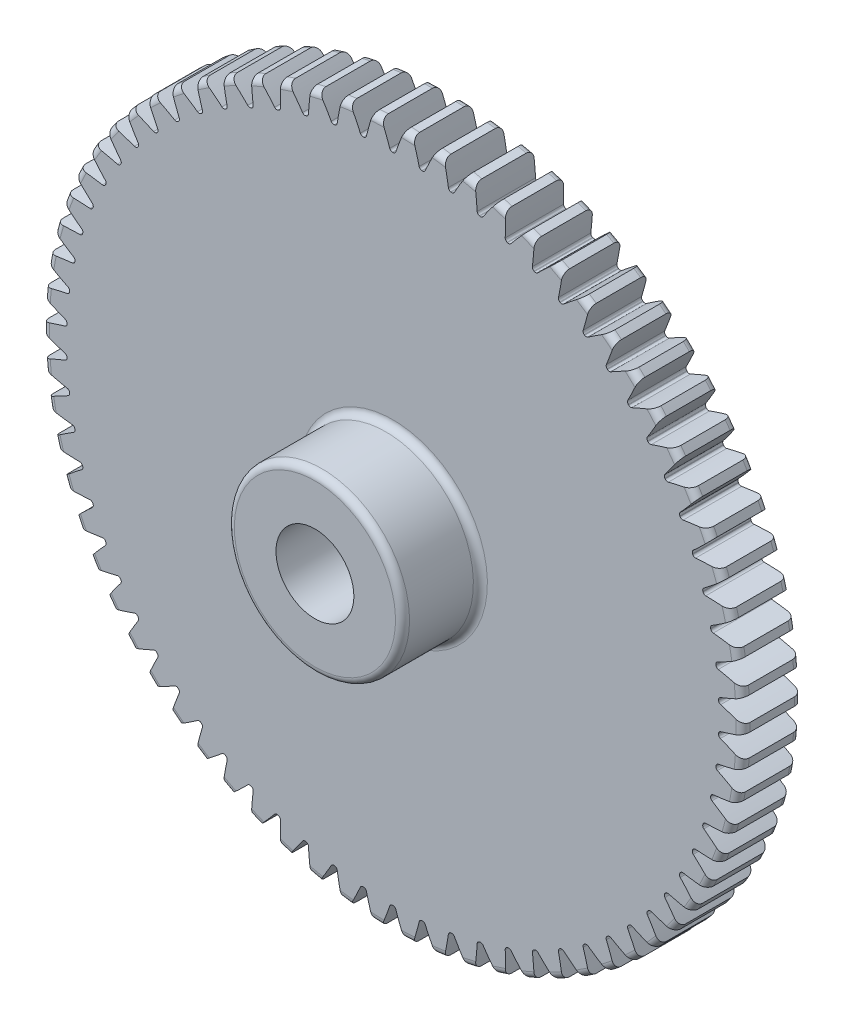
from build123d import *

# Parameters (mm, degrees)
FILLET2_R          = 0.72
CUT_EXTRUDE2_DEPTH = 7
CIRPATTERN1_COUNT  = 70


with BuildPart() as part:
    # Sketch4 → Revolve1 (revolve)
    with BuildSketch(Plane(origin=(0, 0, 0), x_dir=(0, 0, -1), z_dir=(1, 0, 0))):
        Polygon((-14, 4), (-14, 9), (-6, 9), (-6, 36), (0, 36), (0, 4), align=None)
    revolve(axis=Axis((0, 0, 6), (0, 0, 1)))

    # Fillet2
    fillet2_edges = [part.edges().sort_by_distance(p)[0] for p in [
        (0, -36, 0),
        (0, -36, 6),
        (0, -9, 6),
        (0, -9, 14),
    ]]
    fillet(fillet2_edges, radius=FILLET2_R)

    # Sketch7 → Cut-Extrude2 (cut, through all)
    with BuildSketch(Plane.XY.offset(6)):
        with BuildLine():
            ThreePointArc((-0.028170862, 33.499988155), (0, 33.5), (0.028170862, 33.499988155))
            ThreePointArc((0.028170862, 33.499988155), (0.202463766, 33.555627052), (0.312035166, 33.702146032))
            ThreePointArc((0.312035166, 33.702146032), (0.730255925, 34.848906298), (1.188210095, 35.980385723))
            ThreePointArc((1.188210095, 35.980385723), (0, 36), (-1.188210095, 35.980385723))
            ThreePointArc((-1.188210095, 35.980385723), (-0.730255925, 34.848906298), (-0.312035166, 33.702146032))
            ThreePointArc((-0.312035166, 33.702146032), (-0.202463766, 33.555627052), (-0.028170862, 33.499988155))
        make_face()
    cut_extrude2 = extrude(amount=-CUT_EXTRUDE2_DEPTH, mode=Mode.SUBTRACT)

    # CirPattern1: Cut-Extrude2 ×70 about axis
    cirpattern1_axis = Axis((0, 0, 0), (0, 0, 1))
    for i in range(1, CIRPATTERN1_COUNT):
        add(cut_extrude2.rotate(cirpattern1_axis, i * 360 / CIRPATTERN1_COUNT), mode=Mode.SUBTRACT)


solid = part.part
